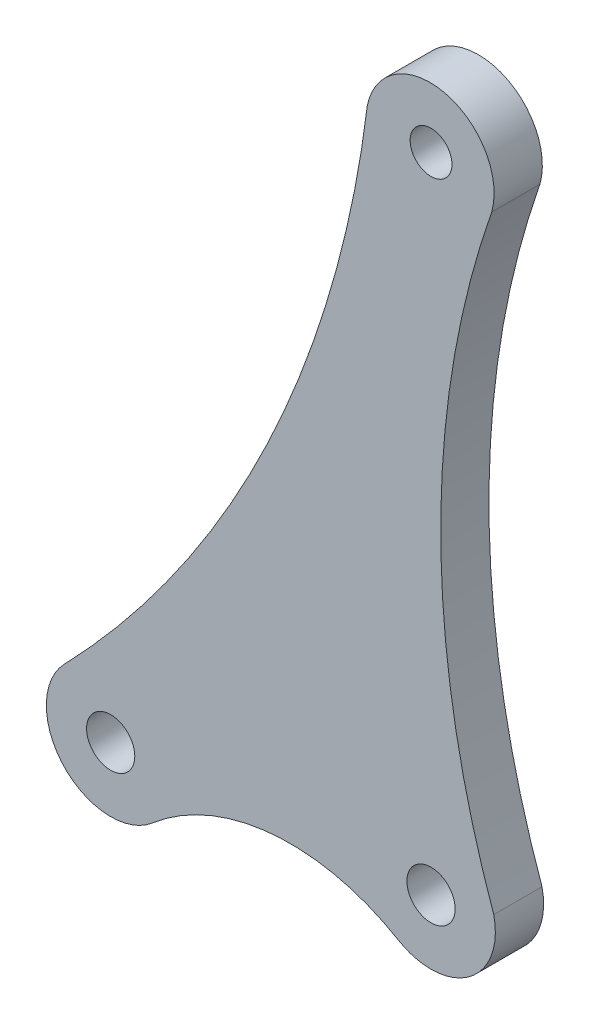
from build123d import *

# Parameters (mm, degrees)
MODEL_R             = 1.3
MODEL_R_2           = 1.5
BOSS_EXTRUDE1_DEPTH = 3


with BuildPart() as part:
    # Model → Boss-Extrude1 (new body)
    with BuildSketch(Plane.XY):
        with BuildLine():
            ThreePointArc((14.161227702, 11.70429003), (14.127993258, 6.180717338), (19.644033131, 5.890434821))
            ThreePointArc((19.644033131, 5.890434821), (27.067718512, 9.016008339), (34.921377151, 7.227053216))
            ThreePointArc((34.921377151, 7.227053216), (35.664878745, 6.883684708), (36.462728707, 6.698936254))
            ThreePointArc((36.462728707, 6.698936254), (39.928001734, 7.988038053), (40.861936188, 11.565420761))
            ThreePointArc((40.861936188, 11.565420761), (37.563797473, 30.440091822), (40.733692306, 49.336723623))
            ThreePointArc((40.733692306, 49.336723623), (37.814731301, 54.297590711), (32.991594421, 51.15627152))
            ThreePointArc((32.991594421, 51.15627152), (26.788825125, 29.897000757), (14.161227702, 11.70429003))
        make_face()
        with Locations((36.961607348, 50.667664276)):
            Circle(MODEL_R, mode=Mode.SUBTRACT)
        with Locations((17.037547355, 8.924717563)):
            Circle(MODEL_R_2, mode=Mode.SUBTRACT)
        with Locations((36.961484604, 10.667620763)):
            Circle(MODEL_R_2, mode=Mode.SUBTRACT)
    extrude(amount=BOSS_EXTRUDE1_DEPTH)


solid = part.part
